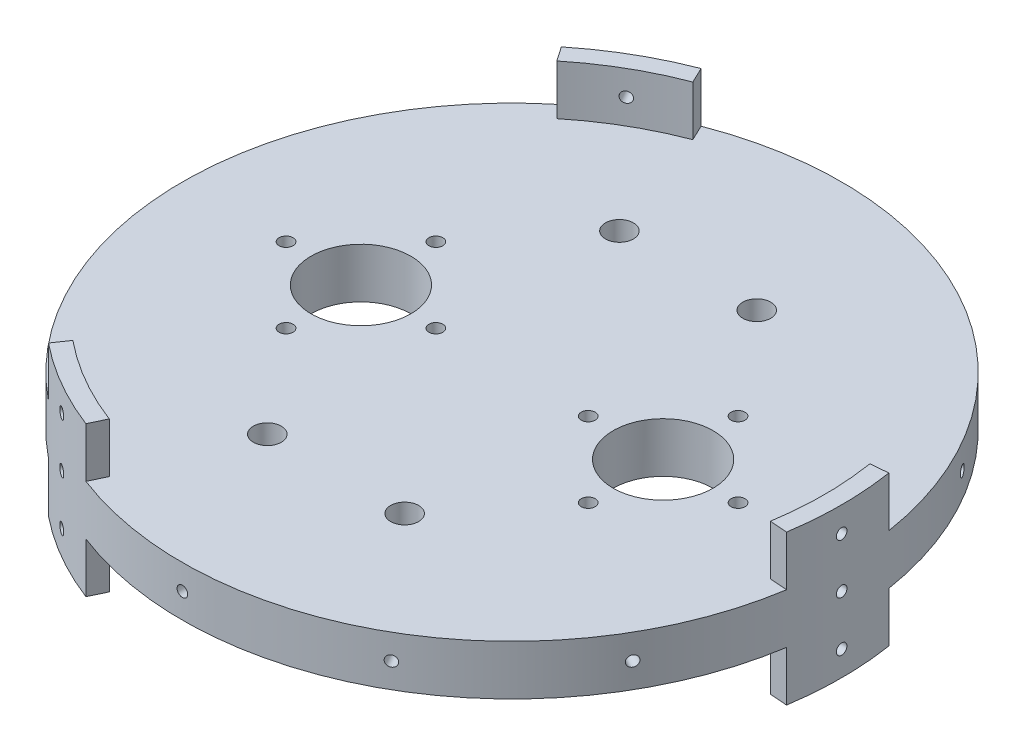
from build123d import *

# Parameters (mm, degrees)
SKETCH1_W           = 127.635
SKETCH1_H           = 127.635
MAIN_PLATE_DEPTH    = 12.7
SKETCH9_R           = 85.725
BOSS_EXTRUDE1_DEPTH = 12.7
SKETCH10_R          = 97.039626961
SKETCH10_R_2        = 83.82
CUT_EXTRUDE1_DEPTH  = 167.64
SKETCH18_R          = 83.82
SKETCH18_R_2        = 79.375
BOSS_EXTRUDE2_DEPTH = 19.05
SKETCH15_R          = 1.35255
CUT_EXTRUDE3_DEPTH  = 15.24
CIRPATTERN1_COUNT   = 12
SKETCH21_R          = 12.7
SKETCH21_R_2        = 1.778
CO2_MOUNTS_DEPTH    = 26.4000001
SKETCH22_R          = 3.556
CUT_EXTRUDE5_DEPTH  = 26.4000001
SKETCH23_R          = 79.375
CUT_EXTRUDE6_DEPTH  = 12.7


with BuildPart() as part:
    # Sketch1 → Main Plate (new body)
    with BuildSketch(Plane(origin=(0, 0, 0), x_dir=(1, 0, 0), z_dir=(0, 1, 0))):
        with Locations((63.8175, 63.8175)):
            Rectangle(SKETCH1_W, SKETCH1_H)
    extrude(amount=MAIN_PLATE_DEPTH)

    # Sketch9 → Boss-Extrude1 (add)
    with BuildSketch(Plane(origin=(0, 12.7, 0), x_dir=(1, 0, 0), z_dir=(0, 1, 0))):
        with Locations((63.8175, 63.8175)):
            Circle(SKETCH9_R)
    extrude(amount=-BOSS_EXTRUDE1_DEPTH)

    # Sketch10 → Cut-Extrude1 (cut)
    with BuildSketch(Plane(origin=(0, 12.7, 0), x_dir=(1, 0, 0), z_dir=(0, 1, 0))):
        with Locations((63.8175, 63.8175)):
            Circle(SKETCH10_R)
        with Locations((63.8175, 63.8175)):
            Circle(SKETCH10_R_2, mode=Mode.SUBTRACT)
    extrude(amount=-CUT_EXTRUDE1_DEPTH, mode=Mode.SUBTRACT)

    # Sketch18 → Boss-Extrude2 (add, symmetric)
    with BuildSketch(Plane(origin=(0, 6.35, 0), x_dir=(1, 0, 0), z_dir=(0, 1, 0))):
        with Locations((63.8175, 63.8175)):
            Circle(SKETCH18_R)
        with Locations((63.8175, 63.8175)):
            Circle(SKETCH18_R_2, mode=Mode.SUBTRACT)
    extrude(amount=BOSS_EXTRUDE2_DEPTH, both=True)

    # Sketch15 → Cut-Extrude3 (cut)
    with BuildSketch(Plane.ZY.offset(20.0025)):
        with Locations((-63.8175, 6.35)):
            Circle(SKETCH15_R)
        with Locations((-63.8175, 19.05)):
            Circle(SKETCH15_R)
        with Locations((-63.8175, -6.35)):
            Circle(SKETCH15_R)
    cut_extrude3 = extrude(amount=-CUT_EXTRUDE3_DEPTH, mode=Mode.SUBTRACT)

    # CirPattern1: Cut-Extrude3 ×12 about axis
    cirpattern1_axis = Axis((63.8175, 0, -63.8175), (0, 1, 0))
    for i in range(1, CIRPATTERN1_COUNT):
        add(cut_extrude3.rotate(cirpattern1_axis, i * 360 / CIRPATTERN1_COUNT), mode=Mode.SUBTRACT)

    # Sketch21 → CO2 Mounts (cut, through all)
    with BuildSketch(Plane(origin=(0, 12.7, 0), x_dir=(1, 0, 0), z_dir=(0, 1, 0))):
        with Locations((102.235, 63.8175)):
            Circle(SKETCH21_R)
        with Locations((102.235, 82.8675)):
            Circle(SKETCH21_R_2)
        with Locations((25.4, 63.8175)):
            Circle(SKETCH21_R)
        with Locations((121.285, 63.8175)):
            Circle(SKETCH21_R_2)
        with Locations((102.235, 44.7675)):
            Circle(SKETCH21_R_2)
        with Locations((83.185, 63.8175)):
            Circle(SKETCH21_R_2)
        with Locations((25.4, 82.8675)):
            Circle(SKETCH21_R_2)
        with Locations((6.35, 63.8175)):
            Circle(SKETCH21_R_2)
        with Locations((25.4, 44.7675)):
            Circle(SKETCH21_R_2)
        with Locations((44.45, 63.8175)):
            Circle(SKETCH21_R_2)
    extrude(amount=-CO2_MOUNTS_DEPTH, mode=Mode.SUBTRACT)

    # Sketch22 → Cut-Extrude5 (cut, through all)
    with BuildSketch(Plane(origin=(0, 12.7, 0), x_dir=(1, 0, 0), z_dir=(0, 1, 0))):
        with Locations((46.355, 108.585)):
            Circle(SKETCH22_R)
        with Locations((81.28, 108.585)):
            Circle(SKETCH22_R)
        with Locations((81.28, 19.05)):
            Circle(SKETCH22_R)
        with Locations((46.355, 19.05)):
            Circle(SKETCH22_R)
    extrude(amount=-CUT_EXTRUDE5_DEPTH, mode=Mode.SUBTRACT)

    # Sketch23 → Cut-Extrude6 (cut)
    with BuildSketch(Plane(origin=(0, 12.7, 0), x_dir=(1, 0, 0), z_dir=(0, 1, 0))):
        with Locations((63.8175, 63.8175)):
            Circle(SKETCH23_R)
        with BuildLine():
            Line((13.678739997, 125.352005526), (7.552270878, 134.237860218))
            Line((7.552270878, 134.237860218), (-19.267108419, 125.320629884))
            Line((-19.267108419, 125.320629884), (-48.79695837, 60.397770071))
            Line((-48.79695837, 60.397770071), (-9.884344094, 7.052469015))
            Line((-9.884344094, 7.052469015), (6.959175986, -7.46308736))
            Line((6.959175986, -7.46308736), (13.678739997, 2.282994474))
            ThreePointArc((13.678739997, 2.282994474), (-15.5575, 63.8175), (13.678739997, 125.352005526))
        make_face()
        with BuildLine():
            Line((142.177324996, 76.471687114), (152.935935453, 77.334437661))
            Line((152.935935453, 77.334437661), (158.623077101, 105.019316613))
            Line((158.623077101, 105.019316613), (117.163156193, 163.054346747))
            Line((117.163156193, 163.054346747), (51.508463168, 156.027684783))
            Line((51.508463168, 156.027684783), (30.515862556, 148.698546693))
            Line((30.515862556, 148.698546693), (35.596435007, 138.00619264))
            ThreePointArc((35.596435007, 138.00619264), (103.505, 132.558266425), (142.177324996, 76.471687114))
        make_face()
        with BuildLine():
            Line((35.596435007, -10.37119264), (30.964293669, -20.119797879))
            Line((30.964293669, -20.119797879), (52.096531318, -38.887446496))
            Line((52.096531318, -38.887446496), (123.086302178, -31.999616818))
            Line((123.086302178, -31.999616818), (149.828380926, 28.372346201))
            Line((149.828380926, 28.372346201), (153.977461458, 50.217040667))
            Line((153.977461458, 50.217040667), (142.177324996, 51.163312886))
            ThreePointArc((142.177324996, 51.163312886), (103.505, -4.923266425), (35.596435007, -10.37119264))
        make_face()
    cut_extrude6 = extrude(amount=CUT_EXTRUDE6_DEPTH, mode=Mode.SUBTRACT)

    # Mirror1: Cut-Extrude6 across plane
    add(cut_extrude6.mirror(Plane.ZX.offset(6.35)), mode=Mode.SUBTRACT)


solid = part.part
